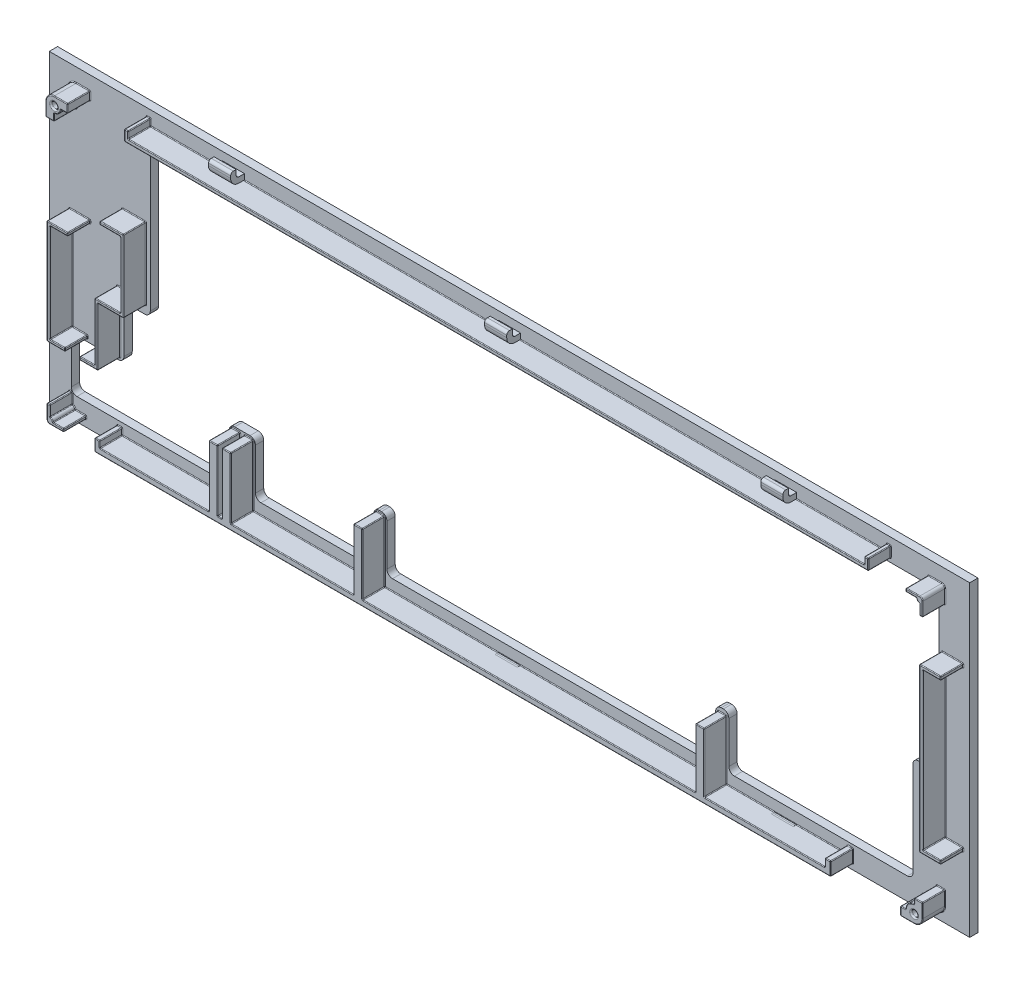
from build123d import *

# Parameters (mm, degrees)
KEYSTENCIL_W        = 333.362491933
KEYSTENCIL_H        = 111.249988971
FACEPLATE_DEPTH     = 3
PLATEMOUNTSKETCH_R  = 1.1
PLATEMOUNT_DEPTH    = 8.15
SCREWHOLESMOOTH_R   = 0.5
FILLET1_R           = 0.25
BOSS_EXTRUDE1_DEPTH = 4
LPATTERN1_COUNT     = 2
LPATTERN1_PITCH     = 100
LPATTERN1_COL_COUNT = 2
LPATTERN1_COL_PITCH = 100


with BuildPart() as part:
    # keystencil → faceplate (new body)
    with BuildSketch(Plane.XY):
        with Locations((-696.479221028, 921.737422614)):
            Rectangle(KEYSTENCIL_W, KEYSTENCIL_H)
        with BuildLine():
            Line((-542.835457632, 969.362417099), (-824.585466994, 969.362417099))
            ThreePointArc((-824.585466994, 969.362417099), (-825.999680556, 968.776630662), (-826.585466994, 967.362417099))
            Line((-826.585466994, 967.362417099), (-826.585466994, 914.212417099))
            ThreePointArc((-826.585466994, 914.212417099), (-827.171253431, 912.798203537), (-828.585466994, 912.212417099))
            Line((-828.585466994, 912.212417099), (-834.110466995, 912.212417099))
            ThreePointArc((-834.110466995, 912.212417099), (-835.524680557, 911.626630662), (-836.110466995, 910.212417099))
            Line((-836.110466995, 910.212417099), (-836.110466995, 895.162417099))
            ThreePointArc((-836.110466995, 895.162417099), (-836.696253433, 893.748203537), (-838.110466995, 893.162417099))
            Line((-838.110466995, 893.162417099), (-853.160466995, 893.162417099))
            ThreePointArc((-853.160466995, 893.162417099), (-854.574680557, 892.576630662), (-855.160466995, 891.162417099))
            Line((-855.160466995, 891.162417099), (-855.160466995, 876.112428128))
            ThreePointArc((-855.160466995, 876.112428128), (-854.574680557, 874.698214566), (-853.160466995, 874.112428128))
            Line((-853.160466995, 874.112428128), (-800.010456721, 874.112428128))
            ThreePointArc((-800.010456721, 874.112428128), (-798.596243159, 874.698214566), (-798.010456721, 876.112428128))
            Line((-798.010456721, 876.112428128), (-798.010456721, 891.162428128))
            ThreePointArc((-798.010456721, 891.162428128), (-797.424670284, 892.576641691), (-796.010456721, 893.162428128))
            Line((-796.010456721, 893.162428128), (-790.485466995, 893.162428128))
            ThreePointArc((-790.485466995, 893.162428128), (-789.071253433, 892.576641691), (-788.485466995, 891.162428128))
            Line((-788.485466995, 891.162428128), (-788.485466995, 876.112428128))
            ThreePointArc((-788.485466995, 876.112428128), (-787.899680557, 874.698214566), (-786.485466995, 874.112428128))
            Line((-786.485466995, 874.112428128), (-747.62295672, 874.112428128))
            ThreePointArc((-747.62295672, 874.112428128), (-746.208743158, 874.698214566), (-745.62295672, 876.112428128))
            Line((-745.62295672, 876.112428128), (-745.62295672, 891.162428128))
            ThreePointArc((-745.62295672, 891.162428128), (-745.037170282, 892.576641691), (-743.62295672, 893.162428128))
            Line((-743.62295672, 893.162428128), (-742.860466994, 893.162428128))
            ThreePointArc((-742.860466994, 893.162428128), (-741.446253431, 892.576641691), (-740.860466994, 891.162428128))
            Line((-740.860466994, 891.162428128), (-740.860466994, 876.112428128))
            ThreePointArc((-740.860466994, 876.112428128), (-740.274680556, 874.698214566), (-738.860466994, 874.112428128))
            Line((-738.860466994, 874.112428128), (-623.79795672, 874.112428128))
            ThreePointArc((-623.79795672, 874.112428128), (-622.383743158, 874.698214566), (-621.79795672, 876.112428128))
            Line((-621.79795672, 876.112428128), (-621.79795672, 891.162428128))
            ThreePointArc((-621.79795672, 891.162428128), (-621.212170282, 892.576641691), (-619.79795672, 893.162428128))
            Line((-619.79795672, 893.162428128), (-619.035466994, 893.162428128))
            ThreePointArc((-619.035466994, 893.162428128), (-617.621253431, 892.576641691), (-617.035466994, 891.162428128))
            Line((-617.035466994, 891.162428128), (-617.035466994, 876.112428128))
            ThreePointArc((-617.035466994, 876.112428128), (-616.449680556, 874.698214566), (-615.035466994, 874.112428128))
            Line((-615.035466994, 874.112428128), (-552.36045672, 874.112428128))
            ThreePointArc((-552.36045672, 874.112428128), (-550.946243158, 874.698214566), (-550.36045672, 876.112428128))
            Line((-550.36045672, 876.112428128), (-550.36045672, 910.212217099))
            ThreePointArc((-550.36045672, 910.212217099), (-549.774670282, 911.626430662), (-548.36045672, 912.212217099))
            Line((-548.36045672, 912.212217099), (-542.835468192, 912.212217099))
            ThreePointArc((-542.835468192, 912.212217099), (-541.421254771, 912.798003397), (-540.835468192, 914.212216702))
            Line((-540.835468192, 914.212216702), (-540.835457632, 967.362416702))
            ThreePointArc((-540.835457632, 967.362416702), (-541.421243929, 968.776630521), (-542.835457632, 969.362417099))
        make_face(mode=Mode.SUBTRACT)
    extrude(amount=FACEPLATE_DEPTH)

    # platemountsketch → platemount (add)
    with BuildSketch(Plane.XY.offset(3)):
        with BuildLine():
            Line((-856.34546859, 964.331868939), (-853.29546859, 964.331868939))
            Line((-853.29546859, 964.331868939), (-853.29546859, 966.934835853))
            ThreePointArc((-853.29546859, 966.934835853), (-851.635548682, 967.622397192), (-850.947987344, 969.282317099))
            Line((-850.947987344, 969.282317099), (-848.345643743, 969.282317099))
            Line((-848.345643743, 969.282317099), (-848.345643743, 972.332317099))
            Line((-848.345643743, 972.332317099), (-853.29546859, 972.332317099))
            ThreePointArc((-853.29546859, 972.332317099), (-855.452144272, 971.438992782), (-856.34546859, 969.282317099))
            Line((-856.34546859, 969.282317099), (-856.34546859, 964.331868939))
        make_face()
        with Locations((-853.29546859, 969.282317099)):
            Circle(PLATEMOUNTSKETCH_R, mode=Mode.SUBTRACT)
        with BuildLine():
            Line((-538.74546859, 876.532241362), (-541.79546859, 876.532241362))
            Line((-541.79546859, 876.532241362), (-541.79546859, 874.582317099))
            ThreePointArc((-541.79546859, 874.582317099), (-543.952144272, 873.688992782), (-544.84546859, 871.532317099))
            Line((-544.84546859, 871.532317099), (-546.781748872, 871.532317099))
            Line((-546.781748872, 871.532317099), (-546.781748872, 868.482317099))
            Line((-546.781748872, 868.482317099), (-541.79546859, 868.482317099))
            ThreePointArc((-541.79546859, 868.482317099), (-539.638792907, 869.375641417), (-538.74546859, 871.532317099))
            Line((-538.74546859, 871.532317099), (-538.74546859, 876.532241362))
        make_face()
        with Locations((-541.79546859, 871.532317099)):
            Circle(PLATEMOUNTSKETCH_R, mode=Mode.SUBTRACT)
        with BuildLine():
            Line((-854.822975466, 868.621576211), (-849.822975466, 868.621576211))
            Line((-849.822975466, 868.621576211), (-849.822975466, 869.721576211))
            Line((-849.822975466, 869.721576211), (-853.722975466, 869.721576211))
            ThreePointArc((-853.722975466, 869.721576211), (-854.045158007, 870.49939367), (-854.822975466, 870.821576211))
            Line((-854.822975466, 870.821576211), (-854.822975466, 874.721576211))
            Line((-854.822975466, 874.721576211), (-855.922975466, 874.721576211))
            Line((-855.922975466, 874.721576211), (-855.922975466, 869.721576211))
            ThreePointArc((-855.922975466, 869.721576211), (-855.600792926, 868.943758751), (-854.822975466, 868.621576211))
        make_face()
        with BuildLine():
            Line((-539.817046894, 972.204875356), (-544.817046894, 972.204875356))
            Line((-544.817046894, 972.204875356), (-544.817046894, 971.104875356))
            Line((-544.817046894, 971.104875356), (-540.917046894, 971.104875356))
            ThreePointArc((-540.917046894, 971.104875356), (-540.594864354, 970.327057897), (-539.817046894, 970.004875356))
            Line((-539.817046894, 970.004875356), (-539.817046894, 966.104875356))
            Line((-539.817046894, 966.104875356), (-538.717046894, 966.104875356))
            Line((-538.717046894, 966.104875356), (-538.717046894, 971.104875356))
            ThreePointArc((-538.717046894, 971.104875356), (-539.039229435, 971.882692815), (-539.817046894, 972.204875356))
        make_face()
        Polygon((-826.466985683, 972.204875356), (-559.797968967, 972.204875356), (-559.797968967, 974.704875356), (-558.397968967, 974.704875356), (-558.397968967, 970.807317099), (-559.797968967, 970.807317099), (-826.466985683, 970.807317099), (-827.866985683, 970.807317099), (-827.866985683, 974.704875356), (-826.466985683, 974.704875356), align=None)
        Polygon((-836.75384109, 870.132317099), (-836.75384109, 872.473327368), (-838.568385651, 872.473327368), (-838.568385651, 868.082317099), (-836.75384109, 868.082317099), (-574.10689402, 868.082317099), (-572.05689402, 868.082317099), (-572.05689402, 872.9021664), (-574.10689402, 872.9021664), (-574.10689402, 870.132317099), (-617.835466994, 870.132317099), (-617.835466994, 891.627785803), (-620.99795672, 891.627785803), (-620.99795672, 870.132317099), (-741.660466994, 870.132317099), (-741.660466994, 892.362428128), (-744.82295672, 892.362428128), (-744.82295672, 870.132317099), (-789.285466995, 870.132317099), (-789.285466995, 892.362428128), (-792.445466995, 892.362428128), (-792.445466995, 870.132317099), (-794.050456721, 870.132317099), (-794.050456721, 892.362428128), (-797.210456721, 892.362428128), (-797.210456721, 870.132317099), align=None)
        Polygon((-538.650138888, 949.566474473), (-538.650138888, 893.086843478), (-532.150138888, 893.086843478), (-532.150138888, 891.836843478), (-539.900138888, 891.836843478), (-539.900138888, 893.086843478), (-539.900138888, 949.770909637), (-539.900138888, 950.816474473), (-532.150138888, 950.816474473), (-532.150138888, 949.566474473), align=None)
        Polygon((-855.922975466, 895.25711706), (-855.922975466, 931.045876123), (-855.922975466, 931.891500929), (-848.322975466, 931.891500929), (-848.322975466, 930.791500929), (-854.822975466, 930.791500929), (-854.822975466, 895.25711706), (-849.322975466, 895.25711706), (-849.322975466, 894.156729478), (-855.922975466, 894.156729478), align=None)
        Polygon((-828.171518903, 940.322742601), (-828.171518903, 916.35023765), (-828.171518903, 915.194954212), (-837.468385651, 915.194954212), (-837.468385651, 895.25711706), (-837.468385651, 894.156729478), (-844.068385651, 894.156729478), (-844.068385651, 895.25711706), (-838.568385651, 895.25711706), (-838.568385651, 915.194954212), (-838.568385651, 916.294954212), (-829.270128816, 916.294954212), (-829.270128816, 940.267459163), (-836.752451003, 940.267459163), (-836.752451003, 941.367459163), (-828.171518903, 941.367459163), align=None)
    extrude(amount=PLATEMOUNT_DEPTH)

    # screwholesmooth
    screwholesmooth_edges = [part.edges().sort_by_distance(p)[0] for p in [
        (-542.89546859, 871.532317099, 11.15),
        (-854.39546859, 969.282317099, 11.15),
    ]]
    fillet(screwholesmooth_edges, radius=SCREWHOLESMOOTH_R)

    # Fillet1
    fillet1_edges = [part.edges().sort_by_distance(p)[0] for p in [
        (-854.39546859, 969.282317099, 3),
        (-542.89546859, 871.532317099, 3),
        (-855.922975466, 872.221576211, 11.15),
        (-855.922975466, 874.721576211, 7.075),
        (-855.922975466, 872.221576211, 3),
        (-855.372975466, 874.721576211, 11.15),
        (-854.822975466, 874.721576211, 7.075),
        (-855.372975466, 874.721576211, 3),
        (-854.822975466, 872.771576211, 11.15),
        (-854.822975466, 870.821576211, 7.075),
        (-854.822975466, 872.771576211, 3),
        (-854.045158007, 870.49939367, 11.15),
        (-853.722975466, 869.721576211, 7.075),
        (-854.045158007, 870.49939367, 3),
        (-851.772975466, 869.721576211, 11.15),
        (-849.822975466, 869.721576211, 7.075),
        (-851.772975466, 869.721576211, 3),
        (-849.822975466, 869.171576211, 11.15),
        (-849.822975466, 868.621576211, 7.075),
        (-849.822975466, 869.171576211, 3),
        (-852.322975466, 868.621576211, 11.15),
        (-852.322975466, 868.621576211, 3),
        (-855.600792926, 868.943758751, 11.15),
        (-855.600792926, 868.943758751, 3),
        (-559.097968967, 974.704875356, 11.15),
        (-558.397968967, 974.704875356, 7.075),
        (-559.097968967, 974.704875356, 3),
        (-558.397968967, 972.756096228, 11.15),
        (-558.397968967, 970.807317099, 7.075),
        (-558.397968967, 972.756096228, 3),
        (-693.132477325, 970.807317099, 11.15),
        (-827.866985683, 970.807317099, 7.075),
        (-693.132477325, 970.807317099, 3),
        (-827.866985683, 972.756096228, 11.15),
        (-827.866985683, 974.704875356, 7.075),
        (-827.866985683, 972.756096228, 3),
        (-827.166985683, 974.704875356, 11.15),
        (-826.466985683, 974.704875356, 7.075),
        (-827.166985683, 974.704875356, 3),
        (-826.466985683, 973.454875356, 11.15),
        (-826.466985683, 972.204875356, 7.075),
        (-826.466985683, 973.454875356, 3),
        (-693.132477325, 972.204875356, 11.15),
        (-559.797968967, 972.204875356, 7.075),
        (-693.132477325, 972.204875356, 3),
        (-559.797968967, 973.454875356, 11.15),
        (-559.797968967, 974.704875356, 7.075),
        (-559.797968967, 973.454875356, 3),
        (-538.650138888, 921.326658975, 11.15),
        (-538.650138888, 893.086843478, 7.075),
        (-538.650138888, 921.326658975, 3),
        (-535.400138888, 893.086843478, 11.15),
        (-532.150138888, 893.086843478, 7.075),
        (-535.400138888, 893.086843478, 3),
        (-532.150138888, 892.461843478, 11.15),
        (-532.150138888, 891.836843478, 7.075),
        (-532.150138888, 892.461843478, 3),
        (-536.025138888, 891.836843478, 11.15),
        (-539.900138888, 891.836843478, 7.075),
        (-536.025138888, 891.836843478, 3),
        (-539.900138888, 921.326658975, 11.15),
        (-539.900138888, 950.816474473, 7.075),
        (-539.900138888, 921.326658975, 3),
        (-536.025138888, 950.816474473, 11.15),
        (-532.150138888, 950.816474473, 7.075),
        (-536.025138888, 950.816474473, 3),
        (-532.150138888, 950.191474473, 11.15),
        (-532.150138888, 949.566474473, 7.075),
        (-532.150138888, 950.191474473, 3),
        (-535.400138888, 949.566474473, 11.15),
        (-538.650138888, 949.566474473, 7.075),
        (-535.400138888, 949.566474473, 3),
        (-538.74546859, 874.03227923, 11.15),
        (-538.74546859, 874.03227923, 3),
        (-540.27046859, 876.532241362, 11.15),
        (-538.74546859, 876.532241362, 7.075),
        (-540.27046859, 876.532241362, 3),
        (-541.79546859, 875.55727923, 11.15),
        (-541.79546859, 876.532241362, 7.075),
        (-541.79546859, 875.55727923, 3),
        (-543.952144272, 873.688992782, 11.15),
        (-541.79546859, 874.582317099, 7.075),
        (-543.952144272, 873.688992782, 3),
        (-545.813608731, 871.532317099, 11.15),
        (-544.84546859, 871.532317099, 7.075),
        (-545.813608731, 871.532317099, 3),
        (-546.781748872, 870.007317099, 11.15),
        (-546.781748872, 871.532317099, 7.075),
        (-546.781748872, 870.007317099, 3),
        (-544.288608731, 868.482317099, 11.15),
        (-546.781748872, 868.482317099, 7.075),
        (-544.288608731, 868.482317099, 3),
        (-539.638792907, 869.375641417, 11.15),
        (-539.638792907, 869.375641417, 3),
        (-828.171518903, 928.281206687, 11.15),
        (-828.171518903, 915.194954212, 7.075),
        (-828.171518903, 928.281206687, 3),
        (-832.819952277, 915.194954212, 11.15),
        (-837.468385651, 915.194954212, 7.075),
        (-832.819952277, 915.194954212, 3),
        (-837.468385651, 904.675841845, 11.15),
        (-837.468385651, 894.156729478, 7.075),
        (-837.468385651, 904.675841845, 3),
        (-840.768385651, 894.156729478, 11.15),
        (-844.068385651, 894.156729478, 7.075),
        (-840.768385651, 894.156729478, 3),
        (-844.068385651, 894.706923269, 11.15),
        (-844.068385651, 895.25711706, 7.075),
        (-844.068385651, 894.706923269, 3),
        (-841.318385651, 895.25711706, 11.15),
        (-838.568385651, 895.25711706, 7.075),
        (-841.318385651, 895.25711706, 3),
        (-838.568385651, 905.776035636, 11.15),
        (-838.568385651, 916.294954212, 7.075),
        (-838.568385651, 905.776035636, 3),
        (-833.919257233, 916.294954212, 11.15),
        (-829.270128816, 916.294954212, 7.075),
        (-833.919257233, 916.294954212, 3),
        (-829.270128816, 928.281206687, 11.15),
        (-829.270128816, 940.267459163, 7.075),
        (-829.270128816, 928.281206687, 3),
        (-833.01128991, 940.267459163, 11.15),
        (-836.752451003, 940.267459163, 7.075),
        (-833.01128991, 940.267459163, 3),
        (-836.752451003, 940.817459163, 11.15),
        (-836.752451003, 941.367459163, 7.075),
        (-836.752451003, 940.817459163, 3),
        (-832.461984953, 941.367459163, 11.15),
        (-828.171518903, 941.367459163, 7.075),
        (-832.461984953, 941.367459163, 3),
        (-855.922975466, 913.024115203, 11.15),
        (-855.922975466, 931.891500929, 7.075),
        (-855.922975466, 913.024115203, 3),
        (-852.122975466, 931.891500929, 11.15),
        (-848.322975466, 931.891500929, 7.075),
        (-852.122975466, 931.891500929, 3),
        (-848.322975466, 931.341500929, 11.15),
        (-848.322975466, 930.791500929, 7.075),
        (-848.322975466, 931.341500929, 3),
        (-851.572975466, 930.791500929, 11.15),
        (-854.822975466, 930.791500929, 7.075),
        (-851.572975466, 930.791500929, 3),
        (-854.822975466, 913.024308995, 11.15),
        (-854.822975466, 895.25711706, 7.075),
        (-854.822975466, 913.024308995, 3),
        (-852.072975466, 895.25711706, 11.15),
        (-849.322975466, 895.25711706, 7.075),
        (-852.072975466, 895.25711706, 3),
        (-849.322975466, 894.706923269, 11.15),
        (-849.322975466, 894.156729478, 7.075),
        (-849.322975466, 894.706923269, 3),
        (-852.622975466, 894.156729478, 11.15),
        (-855.922975466, 894.156729478, 7.075),
        (-852.622975466, 894.156729478, 3),
        (-538.717046894, 968.604875356, 11.15),
        (-538.717046894, 966.104875356, 7.075),
        (-538.717046894, 968.604875356, 3),
        (-539.267046894, 966.104875356, 11.15),
        (-539.817046894, 966.104875356, 7.075),
        (-539.267046894, 966.104875356, 3),
        (-539.817046894, 968.054875356, 11.15),
        (-539.817046894, 970.004875356, 7.075),
        (-539.817046894, 968.054875356, 3),
        (-540.594864354, 970.327057897, 11.15),
        (-540.917046894, 971.104875356, 7.075),
        (-540.594864354, 970.327057897, 3),
        (-542.867046894, 971.104875356, 11.15),
        (-544.817046894, 971.104875356, 7.075),
        (-542.867046894, 971.104875356, 3),
        (-544.817046894, 971.654875356, 11.15),
        (-544.817046894, 972.204875356, 7.075),
        (-544.817046894, 971.654875356, 3),
        (-542.317046894, 972.204875356, 11.15),
        (-542.317046894, 972.204875356, 3),
        (-539.039229435, 971.882692815, 11.15),
        (-539.039229435, 971.882692815, 3),
        (-795.630456721, 892.362428128, 11.15),
        (-794.050456721, 892.362428128, 7.075),
        (-795.630456721, 892.362428128, 3),
        (-794.050456721, 881.247372614, 11.15),
        (-794.050456721, 870.132317099, 7.075),
        (-794.050456721, 881.247372614, 3),
        (-793.247961858, 870.132317099, 11.15),
        (-792.445466995, 870.132317099, 7.075),
        (-793.247961858, 870.132317099, 3),
        (-792.445466995, 881.247372614, 11.15),
        (-792.445466995, 892.362428128, 7.075),
        (-792.445466995, 881.247372614, 3),
        (-790.865466995, 892.362428128, 11.15),
        (-789.285466995, 892.362428128, 7.075),
        (-790.865466995, 892.362428128, 3),
        (-789.285466995, 881.247372614, 11.15),
        (-789.285466995, 870.132317099, 7.075),
        (-789.285466995, 881.247372614, 3),
        (-767.054211858, 870.132317099, 11.15),
        (-744.82295672, 870.132317099, 7.075),
        (-767.054211858, 870.132317099, 3),
        (-744.82295672, 881.247372614, 11.15),
        (-744.82295672, 892.362428128, 7.075),
        (-744.82295672, 881.247372614, 3),
        (-743.241711857, 892.362428128, 11.15),
        (-741.660466994, 892.362428128, 7.075),
        (-743.241711857, 892.362428128, 3),
        (-741.660466994, 881.247372614, 11.15),
        (-741.660466994, 870.132317099, 7.075),
        (-741.660466994, 881.247372614, 3),
        (-681.329211857, 870.132317099, 11.15),
        (-620.99795672, 870.132317099, 7.075),
        (-681.329211857, 870.132317099, 3),
        (-620.99795672, 880.880051451, 11.15),
        (-620.99795672, 891.627785803, 7.075),
        (-620.99795672, 880.880051451, 3),
        (-619.416711857, 891.627785803, 11.15),
        (-617.835466994, 891.627785803, 7.075),
        (-619.416711857, 891.627785803, 3),
        (-617.835466994, 880.880051451, 11.15),
        (-617.835466994, 870.132317099, 7.075),
        (-617.835466994, 880.880051451, 3),
        (-595.971180507, 870.132317099, 11.15),
        (-574.10689402, 870.132317099, 7.075),
        (-595.971180507, 870.132317099, 3),
        (-574.10689402, 871.51724175, 11.15),
        (-574.10689402, 872.9021664, 7.075),
        (-574.10689402, 871.51724175, 3),
        (-573.08189402, 872.9021664, 11.15),
        (-572.05689402, 872.9021664, 7.075),
        (-573.08189402, 872.9021664, 3),
        (-572.05689402, 870.49224175, 11.15),
        (-572.05689402, 868.082317099, 7.075),
        (-572.05689402, 870.49224175, 3),
        (-705.312639836, 868.082317099, 11.15),
        (-838.568385651, 868.082317099, 7.075),
        (-705.312639836, 868.082317099, 3),
        (-838.568385651, 870.277822234, 11.15),
        (-838.568385651, 872.473327368, 7.075),
        (-838.568385651, 870.277822234, 3),
        (-837.66111337, 872.473327368, 11.15),
        (-836.75384109, 872.473327368, 7.075),
        (-837.66111337, 872.473327368, 3),
        (-836.75384109, 871.302822234, 11.15),
        (-836.75384109, 870.132317099, 7.075),
        (-836.75384109, 871.302822234, 3),
        (-816.982148906, 870.132317099, 11.15),
        (-797.210456721, 870.132317099, 7.075),
        (-816.982148906, 870.132317099, 3),
        (-797.210456721, 881.247372614, 11.15),
        (-797.210456721, 892.362428128, 7.075),
        (-797.210456721, 881.247372614, 3),
        (-850.820556167, 972.332317099, 11.15),
        (-848.345643743, 972.332317099, 7.075),
        (-850.820556167, 972.332317099, 3),
        (-855.452144272, 971.438992782, 11.15),
        (-855.452144272, 971.438992782, 3),
        (-856.34546859, 966.807093019, 11.15),
        (-856.34546859, 966.807093019, 3),
        (-854.82046859, 964.331868939, 11.15),
        (-856.34546859, 964.331868939, 7.075),
        (-854.82046859, 964.331868939, 3),
        (-853.29546859, 965.633352396, 11.15),
        (-853.29546859, 964.331868939, 7.075),
        (-853.29546859, 965.633352396, 3),
        (-851.635548682, 967.622397192, 11.15),
        (-853.29546859, 966.934835853, 7.075),
        (-851.635548682, 967.622397192, 3),
        (-849.646815544, 969.282317099, 11.15),
        (-850.947987344, 969.282317099, 7.075),
        (-849.646815544, 969.282317099, 3),
        (-848.345643743, 970.807317099, 11.15),
        (-848.345643743, 969.282317099, 7.075),
        (-848.345643743, 970.807317099, 3),
    ]]
    fillet(fillet1_edges, radius=FILLET1_R)

    # Sketch2 → Boss-Extrude1 (add, symmetric)
    with BuildSketch(Plane(origin=(-696.477975062, 0, 0), x_dir=(0, 0, -1), z_dir=(1, 0, 0))):
        with BuildLine():
            Line((-3, 974.362417099), (-5.052740072, 974.362417099))
            ThreePointArc((-5.052740072, 974.362417099), (-5.725690338, 974.674880381), (-6, 975.364263854))
            Line((-6, 975.364263854), (-6, 977.137185248))
            Line((-6, 977.137185248), (-7, 977.137185248))
            ThreePointArc((-7, 977.137185248), (-7.707106781, 976.844292029), (-8, 976.137185248))
            Line((-8, 976.137185248), (-8, 975.364263854))
            ThreePointArc((-8, 975.364263854), (-7.156155451, 973.245007341), (-5.052740072, 972.362417099))
            Line((-5.052740072, 972.362417099), (-3, 972.362417099))
            Line((-3, 972.362417099), (-3, 974.362417099))
        make_face()
        with BuildLine():
            Line((-3, 867.612428128), (-5.063508327, 867.612428128))
            ThreePointArc((-5.063508327, 867.612428128), (-5.675880763, 867.402997543), (-6.031754163, 866.862428128))
            ThreePointArc((-6.031754163, 866.862428128), (-6.91283939, 866.568781111), (-7.784300125, 866.889866665))
            Line((-7.784300125, 866.889866665), (-5.96341691, 869.094444831))
            ThreePointArc((-5.96341691, 869.094444831), (-4.928781557, 869.897962804), (-3.650382237, 870.183981379))
            Line((-3.650382237, 870.183981379), (-3, 870.183981379))
            Line((-3, 870.183981379), (-3, 867.612428128))
        make_face()
    boss_extrude1 = extrude(amount=BOSS_EXTRUDE1_DEPTH, both=True)

    # LPattern1: Boss-Extrude1 ×2
    with Locations(*[(-i * LPATTERN1_PITCH, 0, 0) for i in range(1, LPATTERN1_COUNT)]):
        add(boss_extrude1)

    # LPattern1 col: Boss-Extrude1 ×2
    with Locations(*[(i * LPATTERN1_COL_PITCH, 0, 0) for i in range(1, LPATTERN1_COL_COUNT)]):
        add(boss_extrude1)


solid = part.part
